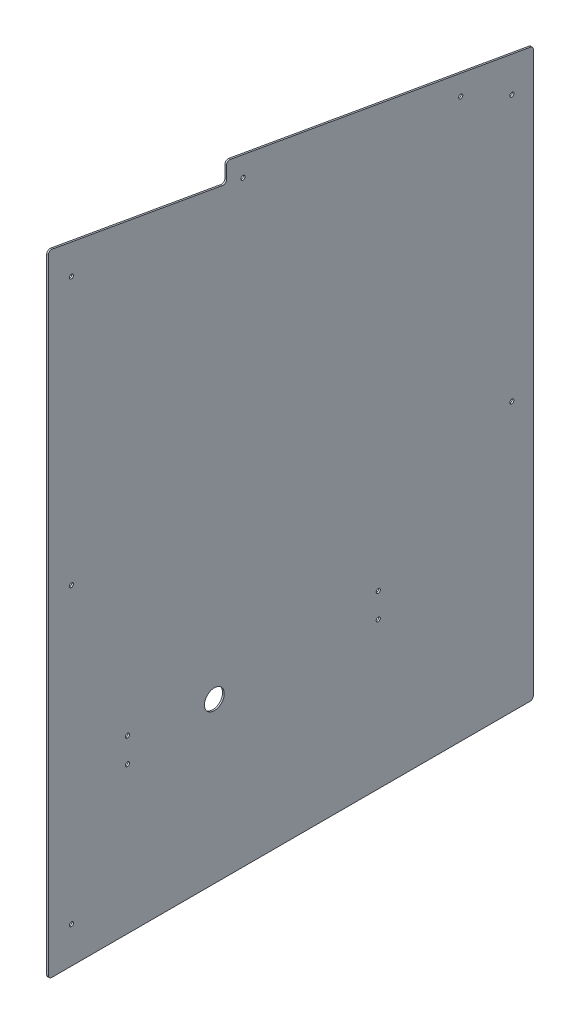
from build123d import *

# Parameters (mm, degrees)
BOSS_EXTRUDE1_DEPTH            = 3.175
SKETCH2_R                      = 19.05
CUT_EXTRUDE1_DEPTH             = 4.175
FILLET1_R                      = 6.35
F_5_16_0_3125_DIAMETER_HOLE1_D = 7.9375


with BuildPart() as part:
    # Sketch1 → Boss-Extrude1 (new body)
    with BuildSketch(Plane(origin=(0, 0, 0), x_dir=(0, 0, -1), z_dir=(1, 0, 0))):
        Polygon((0, 0), (933.45, 0), (933.45, 1089.025), (342.9, 1193.154898457), (342.9, 1154.467144545), (0, 1214.929666229), align=None)
    extrude(amount=BOSS_EXTRUDE1_DEPTH)

    # Sketch2 → Cut-Extrude1 (cut, through all)
    with BuildSketch(Plane(origin=(3.175, 0, 0), x_dir=(0, 0, -1), z_dir=(1, 0, 0))):
        with Locations((319.532, 307.34)):
            Circle(SKETCH2_R)
    extrude(amount=-CUT_EXTRUDE1_DEPTH, mode=Mode.SUBTRACT)

    # Fillet1
    fillet1_edges = [part.edges().sort_by_distance(p)[0] for p in [
        (1.5875, 1214.929666229, 0),
        (1.5875, 1154.467144545, -342.9),
        (1.5875, 1193.154898457, -342.9),
        (1.5875, 1089.025, -933.45),
        (1.5875, 0, -933.45),
        (1.5875, 0, 0),
    ]]
    fillet(fillet1_edges, radius=FILLET1_R)

    # 5/16 (0.3125) Diameter Hole1 (through all)
    with Locations(Plane(origin=(3.175, 0, 0), x_dir=(0, 0, -1), z_dir=(1, 0, 0))):
        with Locations((44.45, 1149.35), (44.45, 635), (152.4, 330.2), (152.4, 282.575), (635, 330.2), (635, 282.575), (892.175, 517.525), (892.175, 1028.7), (374.65, 1148.868762907), (793.75, 1074.970125292), (44.45, 69.85)):
            Hole(F_5_16_0_3125_DIAMETER_HOLE1_D / 2)


solid = part.part
